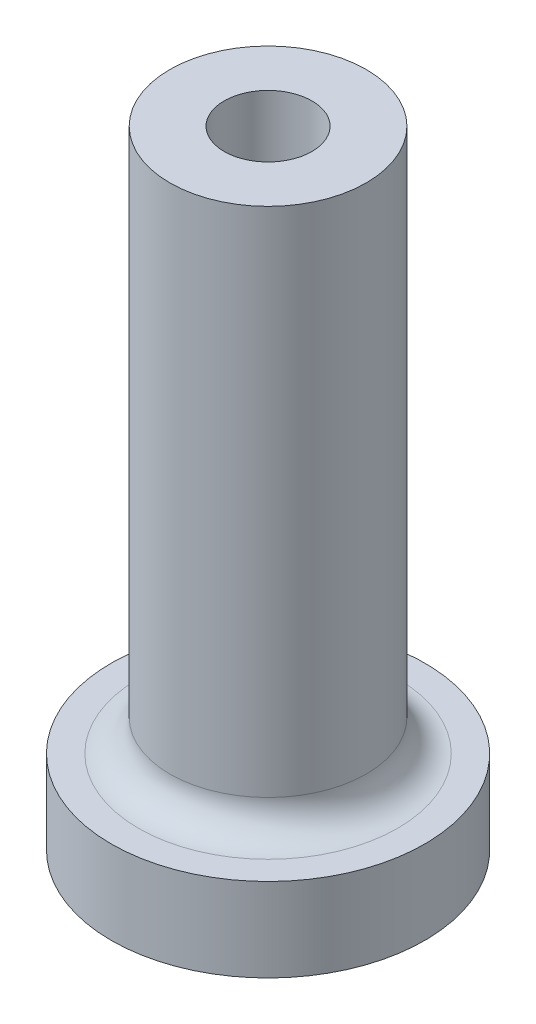
from build123d import *

# Parameters (mm, degrees)
SKETCH1_R           = 7.5
SKETCH1_R_2         = 4.7
SKETCH1_R_3         = 2.1
BOSS_EXTRUDE1_DEPTH = 4
BOSS_EXTRUDE2_START = 4
SKETCH1_3_R         = 4.7
SKETCH1_3_R_2       = 2.1
BOSS_EXTRUDE2_DEPTH = 26
CUT_EXTRUDE1_START  = 30
SKETCH1_4_R         = 2.1
CUT_EXTRUDE1_DEPTH  = 10
FILLET1_R           = 1.5


with BuildPart() as part:
    # Sketch1 → Boss-Extrude1 (new body)
    with BuildSketch(Plane(origin=(0, 0, 0), x_dir=(1, 0, 0), z_dir=(0, 1, 0))):
        with Locations(Location((0, 0, 0), (0, 0, 270))):
            Circle(SKETCH1_R)
        Circle(SKETCH1_R_2, mode=Mode.SUBTRACT)
        Circle(SKETCH1_R_2)
        Circle(SKETCH1_R_3, mode=Mode.SUBTRACT)
        Circle(SKETCH1_R_3)
    extrude(amount=BOSS_EXTRUDE1_DEPTH)

    # Sketch1_3 → Boss-Extrude2 (add)
    with BuildSketch(Plane(origin=(0, 0, 0), x_dir=(1, 0, 0), z_dir=(0, 1, 0)).offset(BOSS_EXTRUDE2_START)):
        with Locations(Location((0, 0, 0), (0, 0, 90))):
            Circle(SKETCH1_3_R)
        Circle(SKETCH1_3_R_2, mode=Mode.SUBTRACT)
        Circle(SKETCH1_3_R_2)
    extrude(amount=BOSS_EXTRUDE2_DEPTH)

    # Sketch1_4 → Cut-Extrude1 (cut)
    with BuildSketch(Plane(origin=(0, 0, 0), x_dir=(1, 0, 0), z_dir=(0, 1, 0)).offset(CUT_EXTRUDE1_START)):
        with Locations(Location((0, 0, 0), (0, 0, 270))):
            Circle(SKETCH1_4_R)
    extrude(amount=-CUT_EXTRUDE1_DEPTH, mode=Mode.SUBTRACT)

    # Fillet1
    fillet1_edges = [part.edges().sort_by_distance(p)[0] for p in [
        (0, 4, 4.7),
    ]]
    fillet(fillet1_edges, radius=FILLET1_R)


solid = part.part
